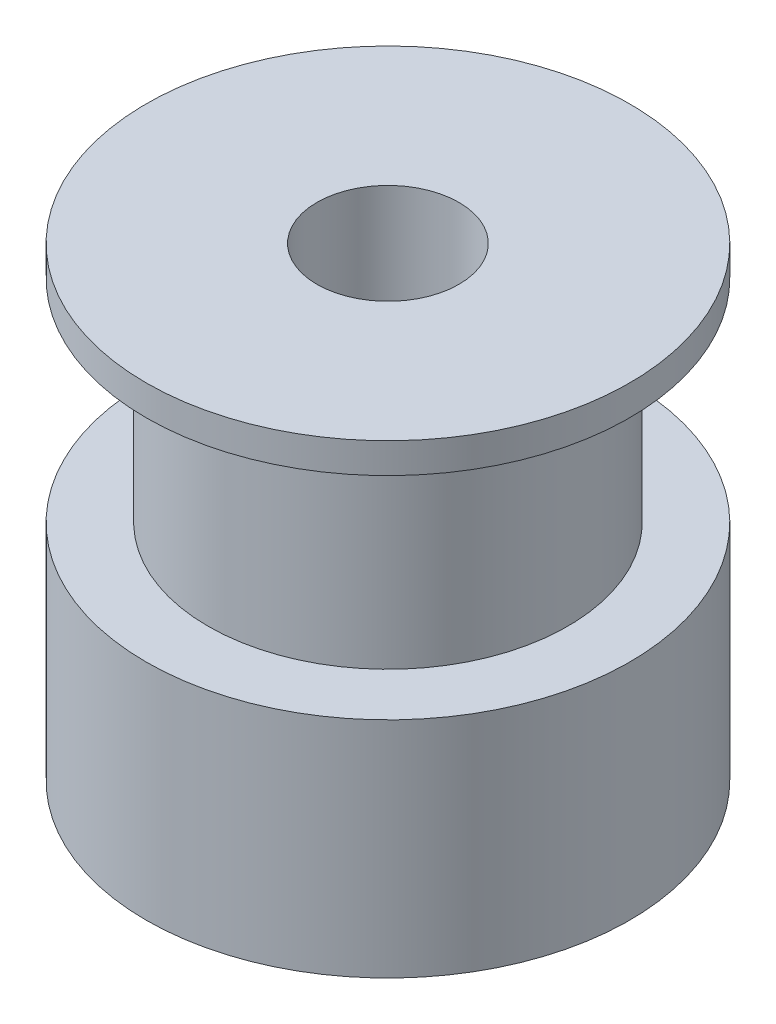
from build123d import *

# Parameters (mm, degrees)
SKETCH1_R           = 8
BOSS_EXTRUDE1_DEPTH = 7.4
SKETCH2_R           = 5.95
BOSS_EXTRUDE2_DEPTH = 7
SKETCH3_R           = 8
BOSS_EXTRUDE3_DEPTH = 1
SKETCH4_R           = 2.35
CUT_EXTRUDE1_DEPTH  = 21


with BuildPart() as part:
    # Sketch1 → Boss-Extrude1 (new body)
    with BuildSketch(Plane(origin=(0, 0, 0), x_dir=(1, 0, 0), z_dir=(0, 1, 0))):
        Circle(SKETCH1_R)
    extrude(amount=BOSS_EXTRUDE1_DEPTH)

    # Sketch2 → Boss-Extrude2 (add)
    with BuildSketch(Plane(origin=(0, 7.4, 0), x_dir=(1, 0, 0), z_dir=(0, 1, 0))):
        Circle(SKETCH2_R)
    extrude(amount=BOSS_EXTRUDE2_DEPTH)

    # Sketch3 → Boss-Extrude3 (add)
    with BuildSketch(Plane(origin=(0, 14.4, 0), x_dir=(1, 0, 0), z_dir=(0, 1, 0))):
        Circle(SKETCH3_R)
    extrude(amount=BOSS_EXTRUDE3_DEPTH)

    # Sketch4 → Cut-Extrude1 (cut)
    with BuildSketch(Plane.XZ):
        Circle(SKETCH4_R)
    extrude(amount=-CUT_EXTRUDE1_DEPTH, mode=Mode.SUBTRACT)


solid = part.part
